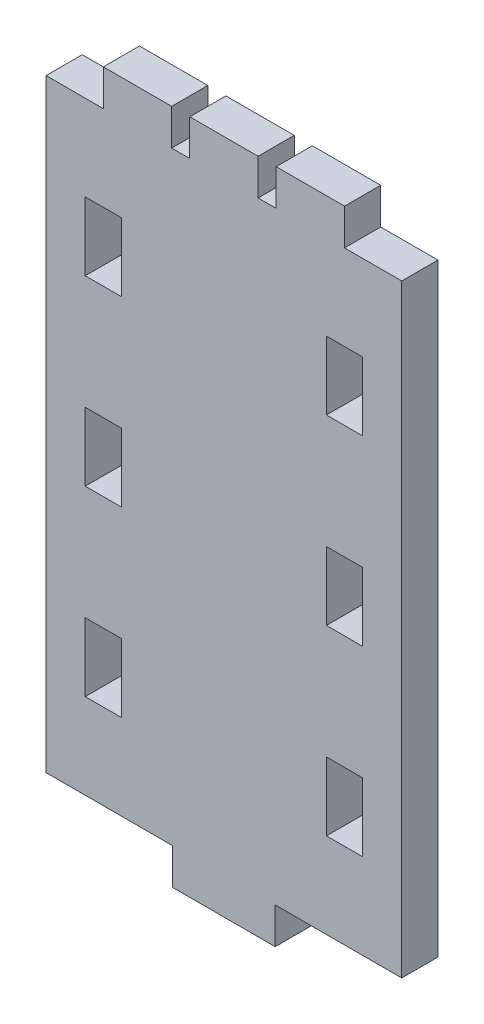
from build123d import *

# Parameters (mm, degrees)
SKETCH1_W           = 3.175
SKETCH1_H           = 6
BOSS_EXTRUDE1_DEPTH = 1.5875


with BuildPart() as part:
    # Sketch1 → Boss-Extrude1 (new body, symmetric)
    with BuildSketch(Plane.XY):
        Polygon((0, 0), (-11.1125, 0), (-11.1125, -3.175), (-20.1125, -3.175), (-20.1125, 0), (-31.225, 0), (-31.225, 53), (-26.2, 53), (-26.2, 56.175), (-20.2, 56.175), (-20.2, 53), (-18.6125, 53), (-18.6125, 56.175), (-12.6125, 56.175), (-12.6125, 53), (-11.025, 53), (-11.025, 56.175), (-5.025, 56.175), (-5.025, 53), (0, 53), align=None)
        with Locations((-5.025, 10.5)):
            Rectangle(SKETCH1_W, SKETCH1_H, mode=Mode.SUBTRACT)
        Polygon((-5.025, 23.5), (-3.4375, 23.5), (-3.4375, 29.5), (-6.6125, 29.5), (-6.6125, 23.5), align=None, mode=Mode.SUBTRACT)
        Polygon((-5.025, 39.5), (-3.4375, 39.5), (-3.4375, 45.5), (-6.6125, 45.5), (-6.6125, 39.5), align=None, mode=Mode.SUBTRACT)
        Polygon((-24.6125, 39.5), (-26.2, 39.5), (-27.7875, 39.5), (-27.7875, 45.5), (-24.6125, 45.5), align=None, mode=Mode.SUBTRACT)
        Polygon((-24.6125, 23.5), (-26.2, 23.5), (-27.7875, 23.5), (-27.7875, 29.5), (-24.6125, 29.5), align=None, mode=Mode.SUBTRACT)
        with Locations((-26.2, 10.5)):
            Rectangle(SKETCH1_W, SKETCH1_H, mode=Mode.SUBTRACT)
    extrude(amount=BOSS_EXTRUDE1_DEPTH, both=True)


solid = part.part
